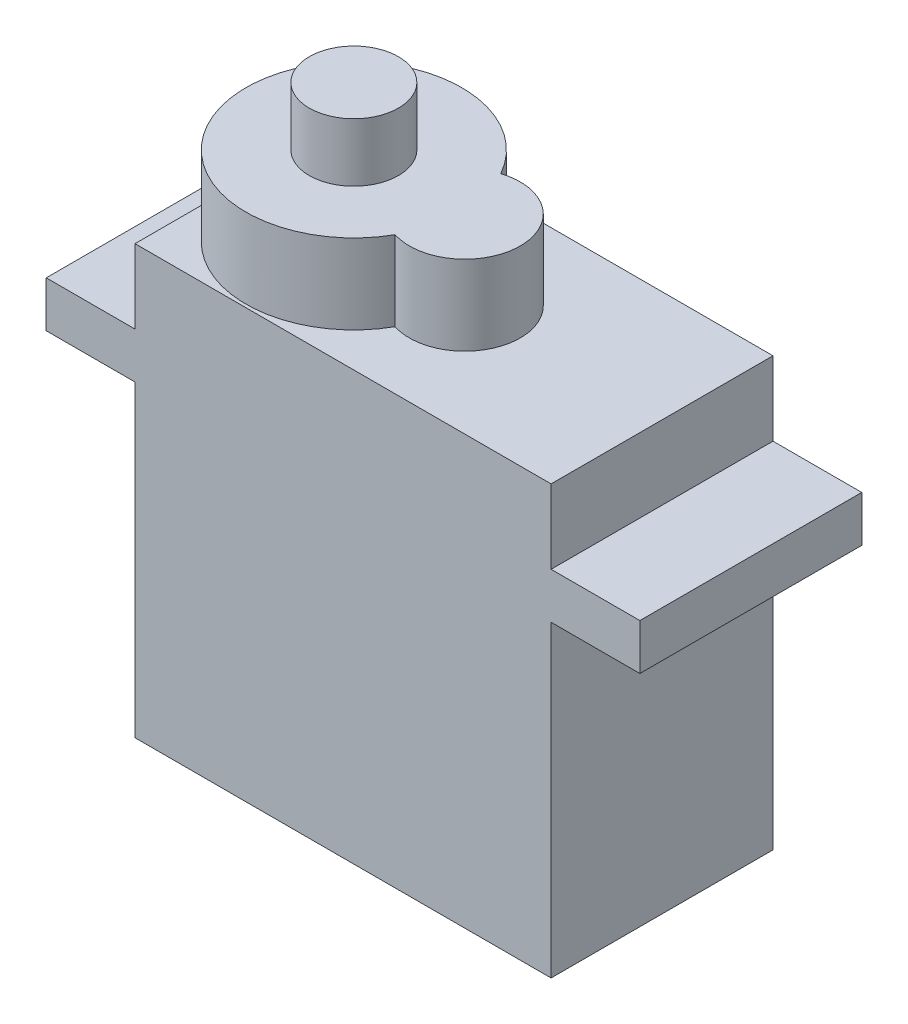
from build123d import *

# Parameters (mm, degrees)
SKETCH1_W           = 22.5
SKETCH1_H           = 12
BOSS_EXTRUDE1_DEPTH = 16.66
SKETCH2_W           = 32.1
SKETCH2_H           = 12
BOSS_EXTRUDE2_DEPTH = 2.48
SKETCH3_W           = 22.5
SKETCH3_H           = 12
BOSS_EXTRUDE3_DEPTH = 4
BOSS_EXTRUDE4_DEPTH = 4.31
SKETCH5_R           = 2.41
BOSS_EXTRUDE5_DEPTH = 3.16
SKETCH6_W           = 3.5
SKETCH6_H           = 1.2
BOSS_EXTRUDE6_DEPTH = 3
BOSS_EXTRUDE6_TAPER = 3


with BuildPart() as part:
    # Sketch1 → Boss-Extrude1 (new body)
    with BuildSketch(Plane(origin=(0, 0, 0), x_dir=(1, 0, 0), z_dir=(0, 1, 0))):
        with Locations((11.25, 6)):
            Rectangle(SKETCH1_W, SKETCH1_H)
    extrude(amount=BOSS_EXTRUDE1_DEPTH)

    # Sketch2 → Boss-Extrude2 (add)
    with BuildSketch(Plane(origin=(0, 16.66, 0), x_dir=(1, 0, 0), z_dir=(0, 1, 0))):
        with Locations((11.25, 6)):
            Rectangle(SKETCH2_W, SKETCH2_H)
    extrude(amount=BOSS_EXTRUDE2_DEPTH)

    # Sketch3 → Boss-Extrude3 (add)
    with BuildSketch(Plane(origin=(0, 19.14, 0), x_dir=(1, 0, 0), z_dir=(0, 1, 0))):
        with Locations((11.25, 6)):
            Rectangle(SKETCH3_W, SKETCH3_H)
    extrude(amount=BOSS_EXTRUDE3_DEPTH)

    # Sketch4 → Boss-Extrude4 (add)
    with BuildSketch(Plane(origin=(0, 23.14, 0), x_dir=(1, 0, 0), z_dir=(0, 1, 0))):
        with BuildLine():
            ThreePointArc((10.92226875, 8.857782648), (0, 6), (10.92226875, 3.142217352))
            ThreePointArc((10.92226875, 3.142217352), (14.835, 6), (10.92226875, 8.857782648))
        make_face()
    extrude(amount=BOSS_EXTRUDE4_DEPTH)

    # Sketch5 → Boss-Extrude5 (add)
    with BuildSketch(Plane(origin=(0, 27.45, 0), x_dir=(1, 0, 0), z_dir=(0, 1, 0))):
        with Locations((5.835, 6)):
            Circle(SKETCH5_R)
    extrude(amount=BOSS_EXTRUDE5_DEPTH)

    # Sketch6 → Boss-Extrude6 (add)
    with BuildSketch(Plane.ZY):
        with Locations((-6, 4.7)):
            Rectangle(SKETCH6_W, SKETCH6_H)
    extrude(amount=BOSS_EXTRUDE6_DEPTH, taper=BOSS_EXTRUDE6_TAPER)


solid = part.part
